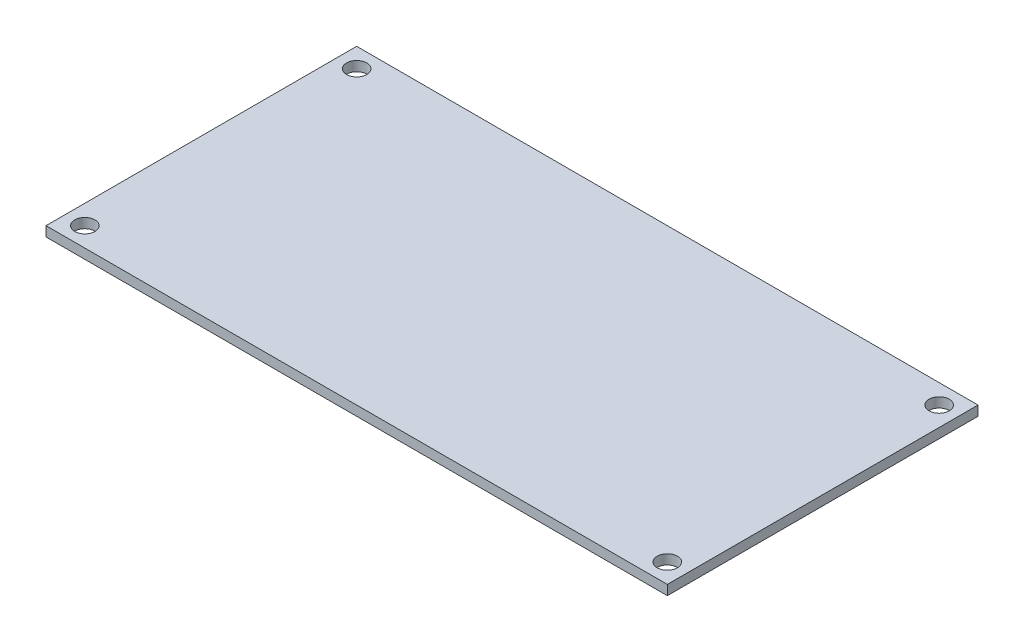
from build123d import *

# Parameters (mm, degrees)
SKETCH1_W             = 101.6
SKETCH1_H             = 50.8
BOSS_EXTRUDE1_DEPTH   = 1.6
F_3_0MM_DOWEL_HOLE1_D = 3.3


with BuildPart() as part:
    # Sketch1 → Boss-Extrude1 (new body)
    with BuildSketch(Plane(origin=(0, 0, 0), x_dir=(1, 0, 0), z_dir=(0, 1, 0))):
        Rectangle(SKETCH1_W, SKETCH1_H)
    extrude(amount=BOSS_EXTRUDE1_DEPTH)

    # Ø3.0mm Dowel Hole1 (through all)
    with Locations(Plane(origin=(0, 1.6, 0), x_dir=(1, 0, 0), z_dir=(0, 1, 0))):
        with Locations((-47.625, 22.225), (47.625, 22.225), (47.625, -22.225), (-47.625, -22.225)):
            Hole(F_3_0MM_DOWEL_HOLE1_D / 2)


solid = part.part
